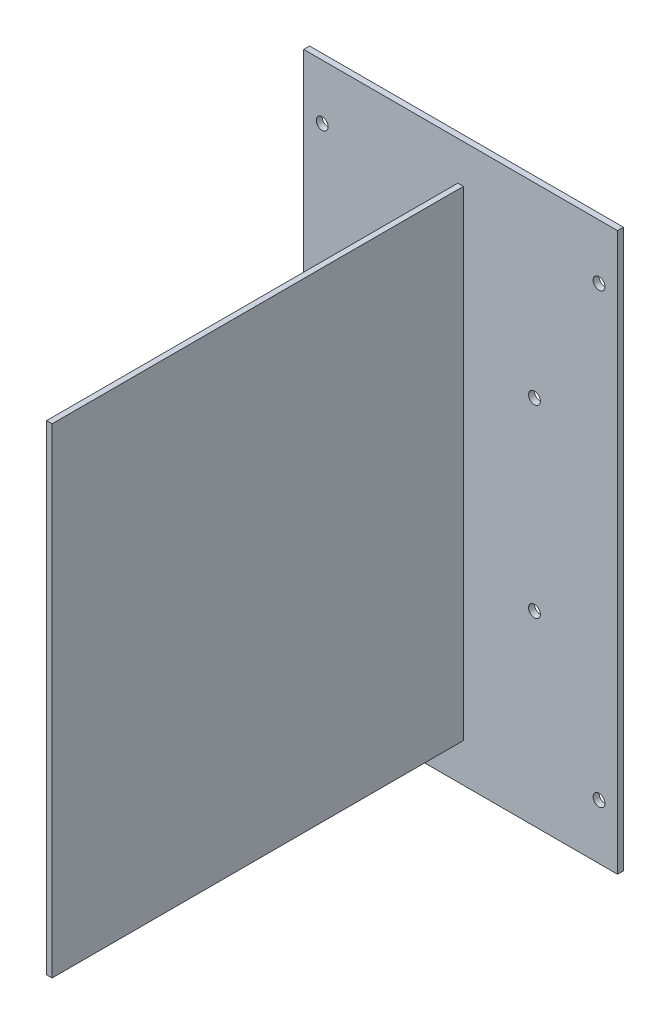
from build123d import *

# Parameters (mm, degrees)
SKETCH2_W           = 85
SKETCH2_H           = 151
SKETCH2_R           = 1.6
BOSS_EXTRUDE1_DEPTH = 1.6
SKETCH3_W           = 1.5
SKETCH3_H           = 130
CUT_EXTRUDE1_DEPTH  = 1.6
SKETCH4_W           = 1.5
SKETCH4_H           = 130
BOSS_EXTRUDE2_DEPTH = 113


with BuildPart() as part:
    # Sketch2 → Boss-Extrude1 (new body)
    with BuildSketch(Plane.XY):
        Rectangle(SKETCH2_W, SKETCH2_H)
        with Locations((37.5, 60.6)):
            Circle(SKETCH2_R, mode=Mode.SUBTRACT)
        with Locations((-37.5, 60.6)):
            Circle(SKETCH2_R, mode=Mode.SUBTRACT)
        with Locations((-37.5, -60.6)):
            Circle(SKETCH2_R, mode=Mode.SUBTRACT)
        with Locations((37.5, -60.6)):
            Circle(SKETCH2_R, mode=Mode.SUBTRACT)
        with Locations((-20, 25)):
            Circle(SKETCH2_R, mode=Mode.SUBTRACT)
        with Locations((20, 25)):
            Circle(SKETCH2_R, mode=Mode.SUBTRACT)
        with Locations((20, -25)):
            Circle(SKETCH2_R, mode=Mode.SUBTRACT)
        with Locations((-20, -25)):
            Circle(SKETCH2_R, mode=Mode.SUBTRACT)
    extrude(amount=BOSS_EXTRUDE1_DEPTH)

    # Sketch3 → Cut-Extrude1 (cut)
    with BuildSketch(Plane.XY.offset(1.6)):
        Rectangle(SKETCH3_W, SKETCH3_H)
    extrude(amount=-CUT_EXTRUDE1_DEPTH, mode=Mode.SUBTRACT)


with BuildPart() as body_2:
    # Sketch4 → Boss-Extrude2 (new body)
    with BuildSketch(Plane(origin=(0, 0, 0), x_dir=(-1, 0, 0), z_dir=(0, 0, -1))):
        Rectangle(SKETCH4_W, SKETCH4_H)
    extrude(amount=-BOSS_EXTRUDE2_DEPTH)


solid = Compound([part.part, body_2.part])
